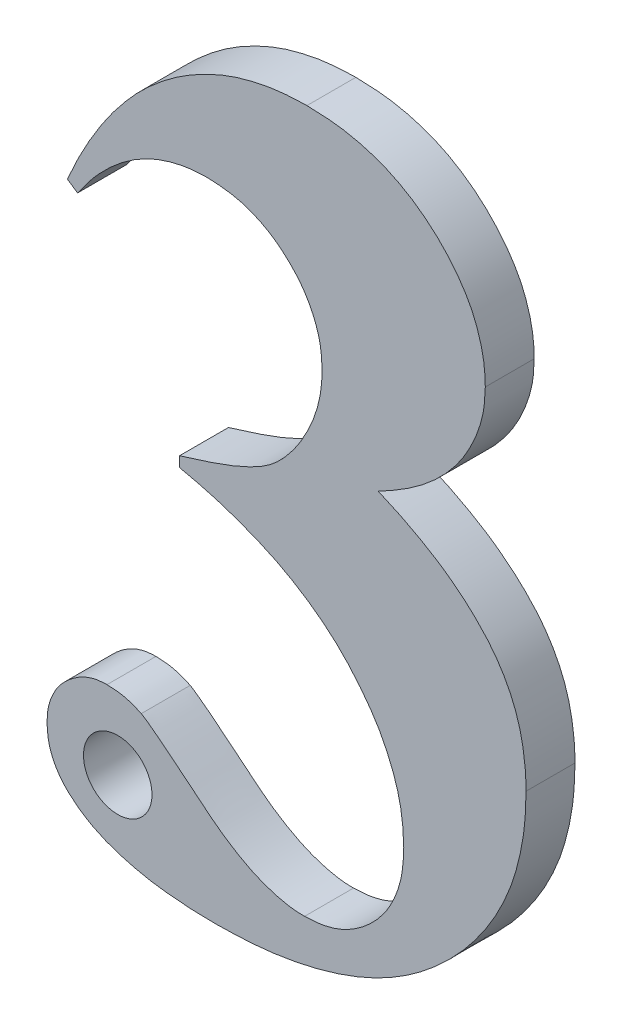
from build123d import *

# Parameters (mm, degrees)
BOSS_EXTRU_1_DEPTH     = 2
D_GAGEMENT_M1_61_D     = 2.8
D_GAGEMENT_M1_61_DEPTH = 50


with BuildPart() as part:
    # Esquisse1 → Boss.-Extru.1 (new body)
    with BuildSketch(Plane.XY):
        with BuildLine():
            Line((17.959030639, 26.205600965), (17.959030639, 26.622267631))
            add(Edge.make_bspline(
                [(17.959030639, 26.622267631), (18.343864616, 26.741397646), (19.054570562, 26.961405273), (20.022450596, 27.297920725), (20.793226188, 27.636579921), (21.41178798, 27.961488766), (21.908982881, 28.341815064), (22.337860827, 28.794274398), (22.745767228, 29.315922342), (23.100821165, 29.915217516), (23.404700203, 30.554453208), (23.629309446, 31.215567304), (23.763709267, 31.883766695), (23.782865125, 32.331325489), (23.792363972, 32.553257215)],
                knots=[0, 0, 0, 0, 0.001208643, 0.002232104, 0.00307162, 0.00373306, 0.004322927, 0.004939873, 0.005598809, 0.006305572, 0.007024936, 0.007718746, 0.008395454, 0.009061078, 0.009061078, 0.009061078, 0.009061078], degree=3))
            add(Edge.make_bspline(
                [(23.792363972, 32.553257215), (23.777386918, 32.852688112), (23.748055085, 33.439108991), (23.476567737, 34.279205766), (23.05714352, 35.057842573), (22.458742382, 35.737618504), (21.754419772, 36.319188825), (20.93943387, 36.736582451), (20.042557045, 36.993204136), (19.414778602, 37.023400823), (19.091843139, 37.038934298)],
                knots=[0, 0, 0, 0, 0.000895934, 0.001754643, 0.002622874, 0.003532401, 0.004453596, 0.005347517, 0.006260578, 0.00722783, 0.00722783, 0.00722783, 0.00722783], degree=3))
            add(Edge.make_bspline(
                [(19.091843139, 37.038934298), (18.837161984, 37.028730471), (18.332048004, 37.008493028), (17.589929818, 36.851833428), (16.873770404, 36.606012306), (16.192473244, 36.248273134), (15.543091586, 35.792770869), (14.921293512, 35.239939745), (14.326825129, 34.587834171), (13.974057459, 34.09576212), (13.792363972, 33.842319715)],
                knots=[0, 0, 0, 0, 0.000763497, 0.001514259, 0.002265782, 0.003028696, 0.003814328, 0.00463992, 0.005520176, 0.006455072, 0.006455072, 0.006455072, 0.006455072], degree=3))
            Line((13.792363972, 33.842319715), (13.375697305, 34.122267631))
            add(Edge.make_bspline(
                [(13.375697305, 34.122267631), (13.510916636, 34.425682129), (13.776186581, 35.020913198), (14.228639052, 35.866364802), (14.704321949, 36.658922192), (15.208701066, 37.393656614), (15.747914733, 38.066450786), (16.30334539, 38.689832329), (16.901929928, 39.242421404), (17.518942178, 39.746587607), (18.161562629, 40.188329144), (18.825333438, 40.56768276), (19.502786648, 40.895073714), (20.200594753, 41.165416985), (20.919701634, 41.362325279), (21.651327947, 41.517971289), (22.403776863, 41.600218242), (22.911118447, 41.614868269), (23.167363972, 41.622267631)],
                knots=[0, 0, 0, 0, 0.000996264, 0.001954446, 0.002874467, 0.003768388, 0.004625516, 0.00545979, 0.006270487, 0.007066623, 0.007848551, 0.008606812, 0.009358081, 0.010104085, 0.010848127, 0.01159251, 0.012345976, 0.013114895, 0.013114895, 0.013114895, 0.013114895], degree=3))
            add(Edge.make_bspline(
                [(23.167363972, 41.622267631), (23.425791745, 41.614983016), (23.933173823, 41.600680825), (24.677057927, 41.518913442), (25.384705116, 41.366868736), (26.058351561, 41.158541993), (26.698214256, 40.8923311), (27.301514696, 40.563537155), (27.870481667, 40.17749841), (28.399513113, 39.738387953), (28.879361945, 39.257419617), (29.303120014, 38.753903461), (29.656569633, 38.225779159), (29.957219958, 37.685185331), (30.173389647, 37.115034391), (30.341250724, 36.530244936), (30.440141633, 35.924669619), (30.452713728, 35.51367148), (30.459030639, 35.307163465)],
                knots=[0, 0, 0, 0, 0.000775423, 0.001522421, 0.002241313, 0.002943503, 0.003635111, 0.004316811, 0.005001179, 0.005694714, 0.006376041, 0.007037065, 0.007665447, 0.008280121, 0.008888244, 0.009490097, 0.01010339, 0.010722736, 0.010722736, 0.010722736, 0.010722736], degree=3))
            add(Edge.make_bspline(
                [(30.459030639, 35.307163465), (30.447158807, 35.032431887), (30.423372861, 34.481990271), (30.207499814, 33.669804093), (29.870845724, 32.875447195), (29.406441017, 32.094801504), (28.793891015, 31.349972333), (28.033907379, 30.648154276), (27.122314827, 29.995513978), (26.440011523, 29.62274401), (26.084030639, 29.428257215)],
                knots=[0, 0, 0, 0, 0.000822892, 0.001648715, 0.00250359, 0.003405746, 0.004363574, 0.005386228, 0.006501031, 0.007717155, 0.007717155, 0.007717155, 0.007717155], degree=3))
            add(Edge.make_bspline(
                [(26.084030639, 29.428257215), (26.323914541, 29.324444629), (26.793646108, 29.121162758), (27.463071461, 28.780326156), (28.091811141, 28.428074399), (28.677960237, 28.061453436), (29.21434292, 27.663484448), (29.717044592, 27.260629192), (30.165030422, 26.824993358), (30.581071213, 26.383454807), (30.947389596, 25.914206817), (31.260635471, 25.415469605), (31.530028979, 24.891065411), (31.752787412, 24.33608079), (31.921404001, 23.749058536), (32.036253088, 23.134083858), (32.110353733, 22.492118171), (32.120507898, 22.054335181), (32.125697305, 21.830600965)],
                knots=[0, 0, 0, 0, 0.000783985, 0.00153517, 0.002252262, 0.002945828, 0.003607332, 0.004255045, 0.004876679, 0.005480184, 0.006074026, 0.006659239, 0.007244489, 0.007840504, 0.008450401, 0.0090735, 0.009715527, 0.010386605, 0.010386605, 0.010386605, 0.010386605], degree=3))
            add(Edge.make_bspline(
                [(32.125697305, 21.830600965), (32.116585867, 21.454528433), (32.09859048, 20.711772938), (31.928747652, 19.621430171), (31.664992357, 18.572417194), (31.282766685, 17.568576979), (30.792488355, 16.608949336), (30.193933235, 15.692700581), (29.494790214, 14.815856568), (28.689901662, 13.993854034), (27.796047655, 13.240547726), (26.82196978, 12.579418652), (25.772537841, 12.021668432), (24.646553648, 11.574509682), (23.449854527, 11.222835447), (22.182246271, 10.969420114), (20.840283071, 10.818660473), (19.92122973, 10.799011028), (19.449916055, 10.788934298)],
                knots=[0, 0, 0, 0, 0.001127506, 0.00222686, 0.003302183, 0.004367448, 0.005441844, 0.006528927, 0.007645326, 0.008800902, 0.009974584, 0.011146496, 0.012326031, 0.013532568, 0.014774762, 0.016063051, 0.017406061, 0.018819781, 0.018819781, 0.018819781, 0.018819781], degree=3))
            add(Edge.make_bspline(
                [(19.449916055, 10.788934298), (19.1394039, 10.791459247), (18.539342266, 10.796338687), (17.673235137, 10.868073843), (16.86860967, 10.955320781), (16.133415709, 11.111218727), (15.455910697, 11.288135838), (14.845916443, 11.515680504), (14.297126694, 11.779418084), (13.974531131, 11.998169888), (13.818405639, 12.104038465)],
                knots=[0, 0, 0, 0, 0.000931194, 0.001799524, 0.002606238, 0.003356999, 0.004051908, 0.004704932, 0.00530763, 0.005872875, 0.005872875, 0.005872875, 0.005872875], degree=3))
            add(Edge.make_bspline(
                [(13.818405639, 12.104038465), (13.622943123, 12.260262087), (13.247911582, 12.560006441), (12.839574491, 13.142561528), (12.583214643, 13.789372904), (12.556103646, 14.24794118), (12.542363972, 14.480340548)],
                knots=[0, 0, 0, 0, 0.000747196, 0.001433636, 0.002109529, 0.002804041, 0.002804041, 0.002804041, 0.002804041], degree=3))
            add(Edge.make_bspline(
                [(12.542363972, 14.480340548), (12.549583483, 14.653080665), (12.563656256, 14.989797732), (12.719906346, 15.469105965), (12.94522911, 15.915073284), (13.274781311, 16.300621428), (13.657259063, 16.62029218), (14.076113089, 16.863324884), (14.526506031, 17.014904891), (14.839398992, 17.030892286), (14.996791055, 17.038934298)],
                knots=[0, 0, 0, 0, 0.000516338, 0.001006482, 0.001498611, 0.002007091, 0.002515571, 0.002987968, 0.00345327, 0.00392423, 0.00392423, 0.00392423, 0.00392423], degree=3))
            add(Edge.make_bspline(
                [(14.996791055, 17.038934298), (15.241018236, 17.027229373), (15.727455987, 17.003916171), (16.174123, 16.809979701), (16.396530639, 16.713413465)],
                knots=[0, 0, 0, 0, 0.000726867, 0.001447732, 0.001447732, 0.001447732, 0.001447732], degree=3))
            add(Edge.make_bspline(
                [(16.396530639, 16.713413465), (16.435892602, 16.690004381), (16.536858718, 16.629958487), (16.710965114, 16.503256943), (16.943128645, 16.326829434), (17.239857644, 16.108629339), (17.580157452, 15.821522929), (17.995048658, 15.502924159), (18.452261546, 15.11427143), (18.959242705, 14.696096576), (19.485532123, 14.275369842), (20.021026068, 13.90069265), (20.551288651, 13.588104953), (21.068195453, 13.323940502), (21.582360269, 13.12767496), (22.085332973, 12.98439783), (22.579693672, 12.884937338), (22.908666405, 12.876431484), (23.069707722, 12.872267631)],
                knots=[0, 0, 0, 0, 0.000137337, 0.00035228, 0.000645249, 0.001012438, 0.001456771, 0.001980405, 0.002581412, 0.003256614, 0.003952102, 0.004602265, 0.005215247, 0.005797557, 0.006341634, 0.006862996, 0.007366113, 0.007848587, 0.007848587, 0.007848587, 0.007848587], degree=3))
            add(Edge.make_bspline(
                [(23.069707722, 12.872267631), (23.338306519, 12.886947683), (23.868808121, 12.915941824), (24.633937345, 13.158470559), (25.328570089, 13.56932886), (25.952733661, 14.117449245), (26.478377861, 14.784984831), (26.85464363, 15.562484997), (27.091396847, 16.419598566), (27.114051321, 17.022149636), (27.125697305, 17.331903048)],
                knots=[0, 0, 0, 0, 0.000804583, 0.001589109, 0.002379689, 0.003210169, 0.004068384, 0.004909841, 0.005786333, 0.006713582, 0.006713582, 0.006713582, 0.006713582], degree=3))
            add(Edge.make_bspline(
                [(27.125697305, 17.331903048), (27.117144204, 17.575296651), (27.100114493, 18.059907185), (26.99489612, 18.780602047), (26.813762292, 19.486642151), (26.544798244, 20.173310162), (26.223836644, 20.853807897), (25.815647288, 21.511948927), (25.333937106, 22.152472296), (24.792001689, 22.783011859), (24.175761846, 23.381013515), (23.486608569, 23.928826911), (22.733652267, 24.432466304), (21.911470291, 24.889571318), (21.017813721, 25.288512907), (20.061694455, 25.64840206), (19.038481137, 25.963905147), (18.324865466, 26.123688225), (17.959030639, 26.205600965)],
                knots=[0, 0, 0, 0, 0.000730212, 0.001453894, 0.002180265, 0.002911782, 0.003663052, 0.004434612, 0.005230189, 0.00606558, 0.006926556, 0.007801983, 0.008703012, 0.009641415, 0.010620427, 0.011636156, 0.012704996, 0.01382932, 0.01382932, 0.01382932, 0.01382932], degree=3))
        make_face()
    extrude(amount=BOSS_EXTRU_1_DEPTH)

    # Dégagement M1.61
    with Locations(Plane.XY.offset(2)):
        with Locations((15.433784775, 14.059510845)):
            Hole(D_GAGEMENT_M1_61_D / 2, depth=D_GAGEMENT_M1_61_DEPTH)


solid = part.part
